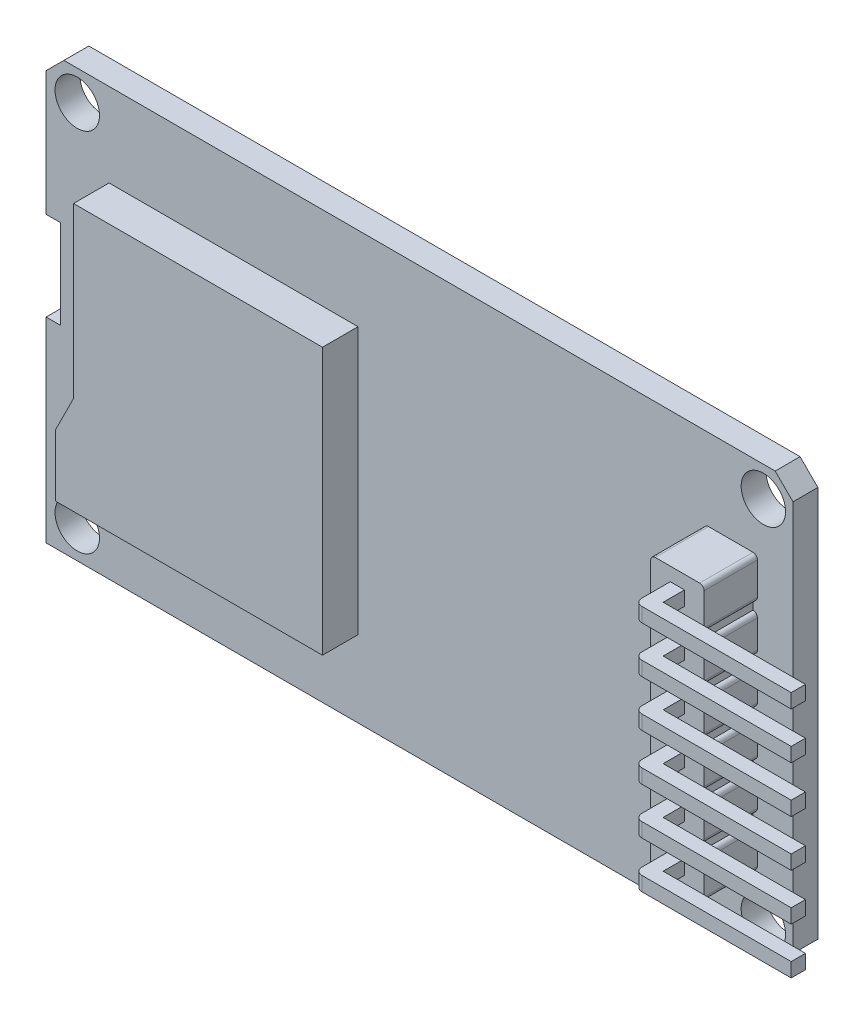
from build123d import *

# Parameters (mm, degrees)
BOSS_EXTRUDE1_DEPTH        = 1.4
F_2_5_2_5_DIAMETER_SLOT1_D = 2.5
BOSS_EXTRUDE2_DEPTH        = 2
BOSS_EXTRUDE3_DEPTH        = 3
SKETCH8_W                  = 0.8
SKETCH8_H                  = 0.8
BOSS_EXTRUDE4_DEPTH        = 2
SKETCH9_W                  = 0.8
SKETCH9_H                  = 0.8
BOSS_EXTRUDE5_DEPTH        = 8
LPATTERN1_COUNT            = 6
LPATTERN1_PITCH            = 2.62
FILLET1_R                  = 0.4


with BuildPart() as part:
    # Sketch1 → Boss-Extrude1 (new body)
    with BuildSketch(Plane.XY):
        Polygon((-17.623529412, 12), (-16.623529412, 13), (23.376470588, 13), (24.376470588, 12), (24.376470588, -10), (23.376470588, -11), (-17.623529412, -11), (-17.623529412, 0), (-16.823529412, 0), (-16.823529412, 5), (-17.623529412, 5), align=None)
    extrude(amount=BOSS_EXTRUDE1_DEPTH)

    # Ø2.5 (2.5) Diameter Slot1 (through all)
    with Locations(Plane.XY.offset(1.4)):
        with Locations((-15.874285672, -9.269193445), (-15.874285672, 11.312714255), (22.710754066, -9.269193445), (22.710754066, 11.312714255)):
            Hole(F_2_5_2_5_DIAMETER_SLOT1_D / 2)

    # Sketch6 → Boss-Extrude2 (add)
    with BuildSketch(Plane.XY.offset(1.4)):
        Polygon((-15.083529412, -6.7), (-0.083529412, -6.7), (-0.083529412, 8.3), (-14.083529412, 8.3), (-14.083529412, -1.2), (-15.083529412, -3.2), align=None)
    extrude(amount=BOSS_EXTRUDE2_DEPTH)

    # Sketch7 → Boss-Extrude3 (add)
    with BuildSketch(Plane.XY.offset(1.4)):
        with BuildLine():
            Line((22.126470588, 6.1), (22.126470588, 5.6))
            ThreePointArc((22.126470588, 5.6), (22.303247284, 5.526776695), (22.376470588, 5.35))
            Line((22.376470588, 5.35), (22.376470588, 3.78))
            ThreePointArc((22.376470588, 3.78), (22.303247284, 3.603223305), (22.126470588, 3.53))
            Line((22.126470588, 3.53), (22.126470588, 3.03))
            ThreePointArc((22.126470588, 3.03), (22.303247284, 2.956776695), (22.376470588, 2.78))
            Line((22.376470588, 2.78), (22.376470588, 1.21))
            ThreePointArc((22.376470588, 1.21), (22.303247284, 1.033223305), (22.126470588, 0.96))
            Line((22.126470588, 0.96), (22.126470588, 0.46))
            ThreePointArc((22.126470588, 0.46), (22.303247284, 0.386776695), (22.376470588, 0.21))
            Line((22.376470588, 0.21), (22.376470588, -1.36))
            ThreePointArc((22.376470588, -1.36), (22.303247284, -1.536776695), (22.126470588, -1.61))
            Line((22.126470588, -1.61), (22.126470588, -2.11))
            ThreePointArc((22.126470588, -2.11), (22.303247284, -2.183223305), (22.376470588, -2.36))
            Line((22.376470588, -2.36), (22.376470588, -3.93))
            ThreePointArc((22.376470588, -3.93), (22.303247284, -4.106776695), (22.126470588, -4.18))
            Line((22.126470588, -4.18), (22.126470588, -4.68))
            ThreePointArc((22.126470588, -4.68), (22.303247284, -4.753223305), (22.376470588, -4.93))
            Line((22.376470588, -4.93), (22.376470588, -6.75))
            ThreePointArc((22.376470588, -6.75), (22.303247284, -6.926776695), (22.126470588, -7))
            Line((22.126470588, -7), (19.626470588, -7))
            ThreePointArc((19.626470588, -7), (19.449693893, -6.926776695), (19.376470588, -6.75))
            Line((19.376470588, -6.75), (19.376470588, -4.93))
            ThreePointArc((19.376470588, -4.93), (19.449693893, -4.753223305), (19.626470588, -4.68))
            Line((19.626470588, -4.68), (19.626470588, -4.18))
            ThreePointArc((19.626470588, -4.18), (19.449693893, -4.106776695), (19.376470588, -3.93))
            Line((19.376470588, -3.93), (19.376470588, -2.36))
            ThreePointArc((19.376470588, -2.36), (19.449693893, -2.183223305), (19.626470588, -2.11))
            Line((19.626470588, -2.11), (19.626470588, -1.61))
            ThreePointArc((19.626470588, -1.61), (19.449693893, -1.536776695), (19.376470588, -1.36))
            Line((19.376470588, -1.36), (19.376470588, 0.21))
            ThreePointArc((19.376470588, 0.21), (19.449693893, 0.386776695), (19.626470588, 0.46))
            Line((19.626470588, 0.46), (19.626470588, 0.96))
            ThreePointArc((19.626470588, 0.96), (19.449693893, 1.033223305), (19.376470588, 1.21))
            Line((19.376470588, 1.21), (19.376470588, 2.78))
            ThreePointArc((19.376470588, 2.78), (19.449693893, 2.956776695), (19.626470588, 3.03))
            Line((19.626470588, 3.03), (19.626470588, 3.53))
            ThreePointArc((19.626470588, 3.53), (19.449693893, 3.603223305), (19.376470588, 3.78))
            Line((19.376470588, 3.78), (19.376470588, 5.35))
            ThreePointArc((19.376470588, 5.35), (19.449693893, 5.526776695), (19.626470588, 5.6))
            Line((19.626470588, 5.6), (19.626470588, 6.1))
            ThreePointArc((19.626470588, 6.1), (19.449693893, 6.173223305), (19.376470588, 6.35))
            Line((19.376470588, 6.35), (19.376470588, 8.17))
            ThreePointArc((19.376470588, 8.17), (19.449693893, 8.346776695), (19.626470588, 8.42))
            Line((19.626470588, 8.42), (22.126470588, 8.42))
            ThreePointArc((22.126470588, 8.42), (22.303247284, 8.346776695), (22.376470588, 8.17))
            Line((22.376470588, 8.17), (22.376470588, 6.35))
            ThreePointArc((22.376470588, 6.35), (22.303247284, 6.173223305), (22.126470588, 6.1))
        make_face()
    extrude(amount=BOSS_EXTRUDE3_DEPTH)

    # Sketch8 → Boss-Extrude4 (add)
    with BuildSketch(Plane.XY.offset(4.4)):
        with Locations((20.876470588, -5.84)):
            Rectangle(SKETCH8_W, SKETCH8_H)
        with Locations((20.876470588, -3.22)):
            Rectangle(SKETCH8_W, SKETCH8_H)
        with Locations((20.876470588, -0.6)):
            Rectangle(SKETCH8_W, SKETCH8_H)
        with Locations((20.876470588, 2.02)):
            Rectangle(SKETCH8_W, SKETCH8_H)
        with Locations((20.876470588, 4.64)):
            Rectangle(SKETCH8_W, SKETCH8_H)
        with Locations((20.876470588, 7.26)):
            Rectangle(SKETCH8_W, SKETCH8_H)
    extrude(amount=BOSS_EXTRUDE4_DEPTH)

    # Sketch9 → Boss-Extrude5 (add)
    with BuildSketch(Plane(origin=(21.276470588, 0, 0), x_dir=(0, 0, -1), z_dir=(1, 0, 0))):
        with Locations((-6, 7.26)):
            Rectangle(SKETCH9_W, SKETCH9_H)
    boss_extrude5 = extrude(amount=BOSS_EXTRUDE5_DEPTH)

    # LPattern1: Boss-Extrude5 ×6
    with Locations(*[(0, -i * LPATTERN1_PITCH, 0) for i in range(1, LPATTERN1_COUNT)]):
        add(boss_extrude5)

    # Fillet1
    fillet1_edges = [part.edges().sort_by_distance(p)[0] for p in [
        (20.476470588, -5.84, 6.4),
        (20.476470588, -3.22, 6.4),
        (20.476470588, -0.6, 6.4),
        (20.476470588, 2.02, 6.4),
        (20.476470588, 4.64, 6.4),
        (20.476470588, 7.26, 6.4),
    ]]
    fillet(fillet1_edges, radius=FILLET1_R)


solid = part.part
